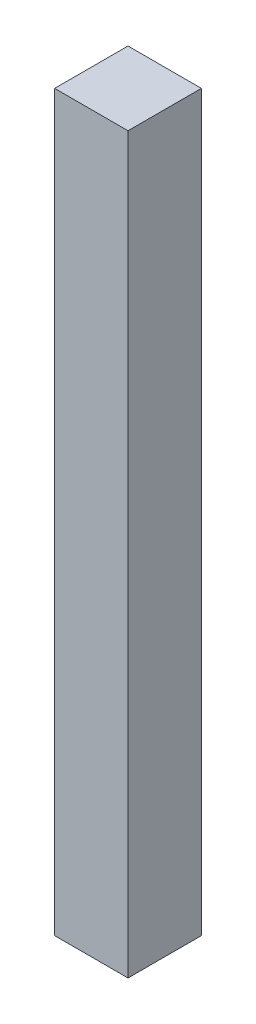
from build123d import *

# Parameters (mm, degrees)
SKETCH1_W           = 20
SKETCH1_H           = 20
BOSS_EXTRUDE1_DEPTH = 200


with BuildPart() as part:
    # Sketch1 → Boss-Extrude1 (new body)
    with BuildSketch(Plane(origin=(0, 0, 0), x_dir=(1, 0, 0), z_dir=(0, 1, 0))):
        Rectangle(SKETCH1_W, SKETCH1_H)
    extrude(amount=BOSS_EXTRUDE1_DEPTH)


solid = part.part
